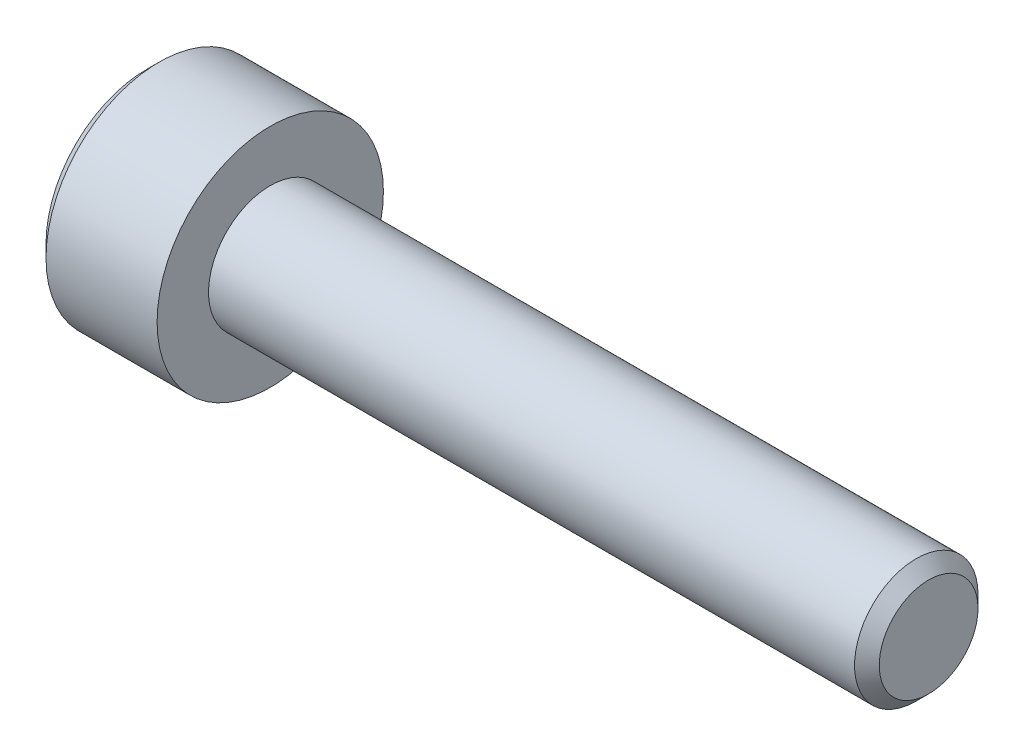
from build123d import *

# Parameters (mm, degrees)
SKETCH_1_W          = 3
SKETCH_1_H          = 2.75
SKETCH_2_R          = 1.5
EXTRUDE_1_DEPTH     = 16
CUT_EXTRUDE_1_DEPTH = 1.3
CHAMFER_1_SIZE      = 0.3


with BuildPart() as part:
    # 草图1 → 旋转1 (revolve)
    with BuildSketch(Plane(origin=(0, 0, 0), x_dir=(-1, 0, 0), z_dir=(0, 0, -1))):
        with Locations((-1.5, 1.375)):
            Rectangle(SKETCH_1_W, SKETCH_1_H)
    revolve(axis=Axis((3, 0, 0), (-1, 0, 0)))

    # 草图2 → 凸台-拉伸1 (add)
    with BuildSketch(Plane(origin=(3, 0, 0), x_dir=(0, 0, -1), z_dir=(1, 0, 0))):
        Circle(SKETCH_2_R)
    extrude(amount=EXTRUDE_1_DEPTH)

    # 草图3 → 切除-拉伸1 (cut)
    with BuildSketch(Plane.ZY):
        Polygon((1.28, 0.739008345), (0, 1.478016689), (-1.28, 0.739008345), (-1.28, -0.739008345), (0, -1.478016689), (1.28, -0.739008345), align=None)
    extrude(amount=-CUT_EXTRUDE_1_DEPTH, mode=Mode.SUBTRACT)

    # 草图4 → 切除-旋转1 (revolve, cut)
    with BuildSketch(Plane.XY):
        Polygon((1.3, 1.28), (1.3, 0), (2.039008345, 0), align=None)
    revolve(axis=Axis((1.3, 0, 0), (1, 0, 0)), mode=Mode.SUBTRACT)

    # 倒角1
    chamfer_1_edges = [part.edges().sort_by_distance(p)[0] for p in [
        (19, 0, 1.5),
        (0, -2.75, 0),
    ]]
    chamfer(chamfer_1_edges, length=CHAMFER_1_SIZE)


solid = part.part
